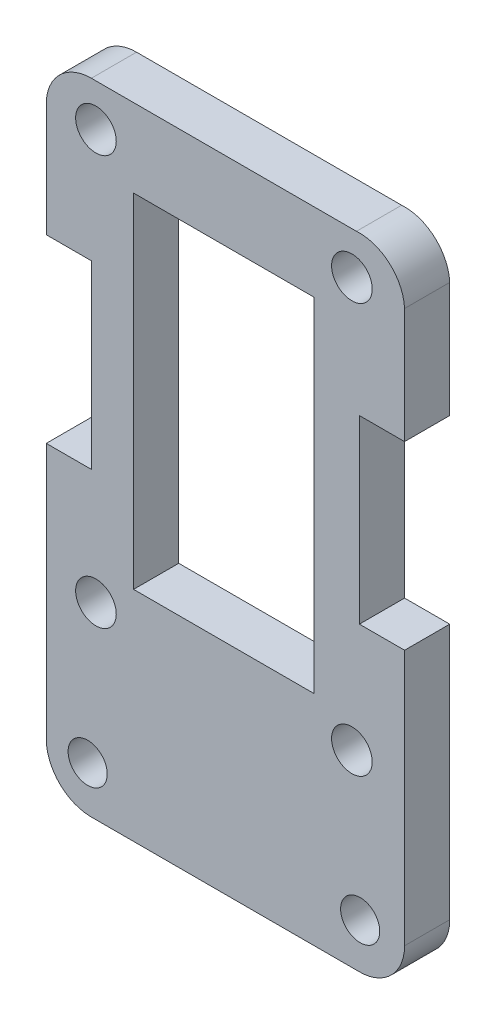
from build123d import *

# Parameters (mm, degrees)
MODEL_R             = 1.350108094
MODEL_R_2           = 1.30010409
MODEL_W             = 12.000960833
MODEL_H             = 22.8
BOSS_EXTRUDE1_DEPTH = 3


with BuildPart() as part:
    # Model → Boss-Extrude1 (new body)
    with BuildSketch(Plane.XY):
        with BuildLine():
            Line((58.668697195, 41.004775949), (61.668697195, 41.004775949))
            Line((61.668697195, 41.004775949), (61.668697195, 24.003921827))
            ThreePointArc((61.668697195, 24.003921827), (60.754304786, 21.847009523), (58.568180571, 21.004842626))
            Line((58.568180571, 21.004842626), (40.767051953, 21.004842626))
            ThreePointArc((40.767051953, 21.004842626), (38.710492919, 21.917586858), (37.866775535, 24.003414768))
            Line((37.866775535, 24.003414768), (37.866775535, 41.004775949))
            Line((37.866775535, 41.004775949), (40.867015743, 41.004775949))
            Line((40.867015743, 41.004775949), (40.867015743, 53.004775949))
            Line((40.867015743, 53.004775949), (37.866775535, 53.004775949))
            Line((37.866775535, 53.004775949), (37.866775535, 60.663449882))
            ThreePointArc((37.866775535, 60.663449882), (38.797636626, 62.682660658), (40.862794137, 63.506577512))
            Line((40.862794137, 63.506577512), (58.472438386, 63.506577512))
            ThreePointArc((58.472438386, 63.506577512), (60.66612789, 62.754918404), (61.668697195, 60.663956941))
            Line((61.668697195, 60.663956941), (61.668697195, 53.004775949))
            Line((61.668697195, 53.004775949), (58.668697195, 53.004775949))
            Line((58.668697195, 53.004775949), (58.668697195, 41.004775949))
        make_face()
        with Locations((41.167245975, 60.70691038)):
            Circle(MODEL_R, mode=Mode.SUBTRACT)
        with Locations((58.168607156, 60.70691038)):
            Circle(MODEL_R, mode=Mode.SUBTRACT)
        with Locations((41.167245975, 33.504732491)):
            Circle(MODEL_R, mode=Mode.SUBTRACT)
        with Locations((58.168607156, 33.504732491)):
            Circle(MODEL_R, mode=Mode.SUBTRACT)
        with Locations((40.617301942, 24.003971828)):
            Circle(MODEL_R_2, mode=Mode.SUBTRACT)
        with Locations((58.718751199, 24.003971828)):
            Circle(MODEL_R_2, mode=Mode.SUBTRACT)
        with Locations((49.667616262, 46.904842626)):
            Rectangle(MODEL_W, MODEL_H, mode=Mode.SUBTRACT)
    extrude(amount=BOSS_EXTRUDE1_DEPTH)


solid = part.part
